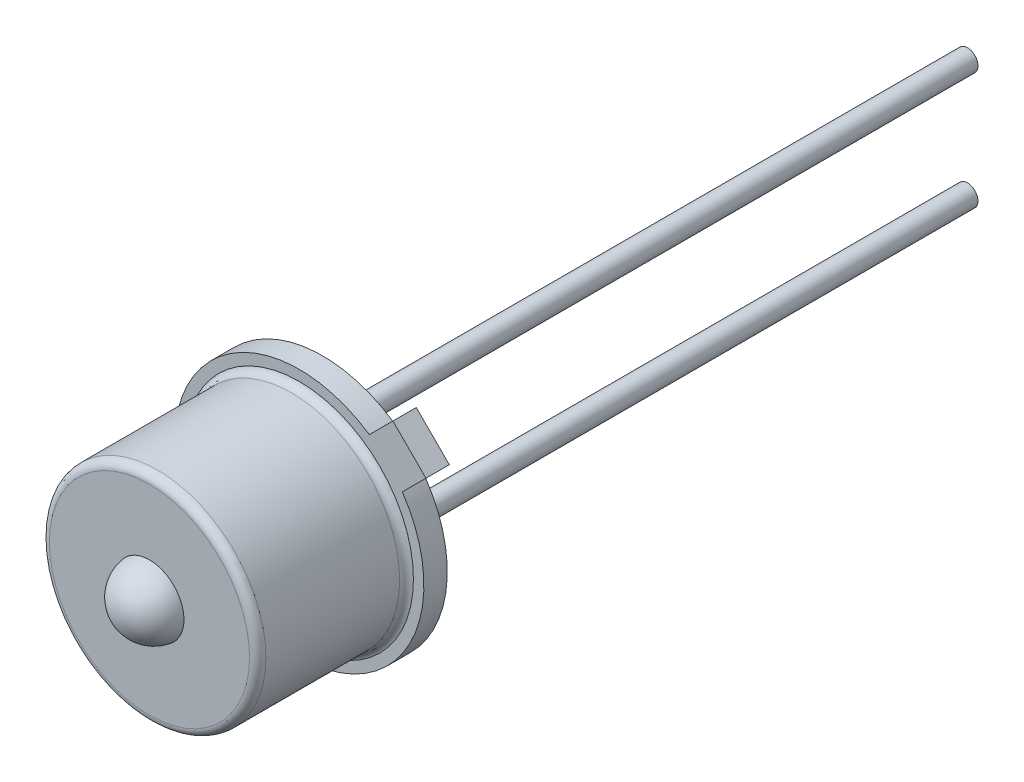
from build123d import *

# Parameters (mm, degrees)
BOSS_EXTRUDE1_DEPTH = 0.5072126
SKETCH7_R           = 0.2286
BOSS_EXTRUDE2_DEPTH = 13.9954
SKETCH8_R           = 0.5072126
BOSS_EXTRUDE3_DEPTH = 0.3381502


with BuildPart() as part:
    # Sketch1 → Boss-Extrude1 (new body)
    with BuildSketch(Plane.XY):
        with BuildLine():
            Line((2.749646661, 2.032339723), (2.032339723, 2.749646661))
            Line((2.032339723, 2.749646661), (1.520216057, 2.237522995))
            ThreePointArc((1.520216057, 2.237522995), (-1.912794554, -1.912794554), (2.237522995, 1.520216057))
            Line((2.237522995, 1.520216057), (2.749646661, 2.032339723))
        make_face()
    extrude(amount=BOSS_EXTRUDE1_DEPTH)

    # Sketch4 → Revolve1 (revolve)
    with BuildSketch(Plane(origin=(0, 0, 0), x_dir=(0, 0, -1), z_dir=(1, 0, 0)), mode=Mode.PRIVATE) as revolve1_sk:
        with BuildLine():
            Line((-0.677937746, 2.3495), (-3.581399897, 2.3495))
            ThreePointArc((-3.581399897, 2.3495), (-3.707123483, 2.297423586), (-3.759199897, 2.1717))
            Line((-3.759199897, 2.1717), (-3.759199897, 0.7493))
            Line((-3.759199897, 0.7493), (-3.606799897, 0.7493))
            Line((-3.606799897, 0.7493), (-3.606799897, 2.1971))
            Line((-3.606799897, 2.1971), (-0.5072126, 2.1971))
            Line((-0.5072126, 2.1971), (-0.5072126, 2.350316811))
            Line((-0.5072126, 2.350316811), (-0.5072126, 2.477643535))
            ThreePointArc((-0.5072126, 2.477643535), (-0.57120462, 2.38509986), (-0.677937746, 2.3495))
        make_face()
    revolve(revolve1_sk.sketch.rotate(Axis((0, 0, 0.5072126), (0, 0, 1)), 90), axis=Axis((0, 0, 0.5072126), (0, 0, 1)))  # turned: the seam where the file's is

    # Sketch7 → Boss-Extrude2 (add)
    with BuildSketch(Plane(origin=(0, 0, 0), x_dir=(-1, 0, 0), z_dir=(0, 0, -1))):
        with Locations(Location((0, -1.27, 0), (0, 0, 180))):  # turned: the seam where the file's is
            Circle(SKETCH7_R)
        with Locations(Location((1.27, 0, 0), (0, 0, 180))):  # turned: the seam where the file's is
            Circle(SKETCH7_R)
        with Locations(Location((0, 1.27, 0), (0, 0, 180))):  # turned: the seam where the file's is
            Circle(SKETCH7_R)
    extrude(amount=BOSS_EXTRUDE2_DEPTH)

    # Sketch8 → Boss-Extrude3 (add)
    with BuildSketch(Plane(origin=(0, 0, 0), x_dir=(-1, 0, 0), z_dir=(0, 0, -1))):
        with Locations(Location((1.264550567, 0, 0), (0, 0, 180))):  # turned: the seam where the file's is
            Circle(SKETCH8_R)
    extrude(amount=BOSS_EXTRUDE3_DEPTH)


with BuildPart() as body_2:
    # Sketch11 → Revolve3 (revolve)
    with BuildSketch(Plane(origin=(0, 0, 0), x_dir=(1, 0, 0), z_dir=(0, 1, 0))):
        with BuildLine():
            Line((0, -4.419599897), (0, -4.216399897))
            ThreePointArc((0, -4.216399897), (-0.355255293, -4.086915389), (-0.543868967, -3.759199897))
            Line((-0.543868967, -3.759199897), (-0.7493, -3.759199897))
            ThreePointArc((-0.7493, -3.759199897), (-0.499394296, -4.230936694), (0, -4.419599897))
        make_face()
    revolve(axis=Axis((0, 0, 3.759199897), (0, 0, 1)))


solid = Compound([part.part, body_2.part])
